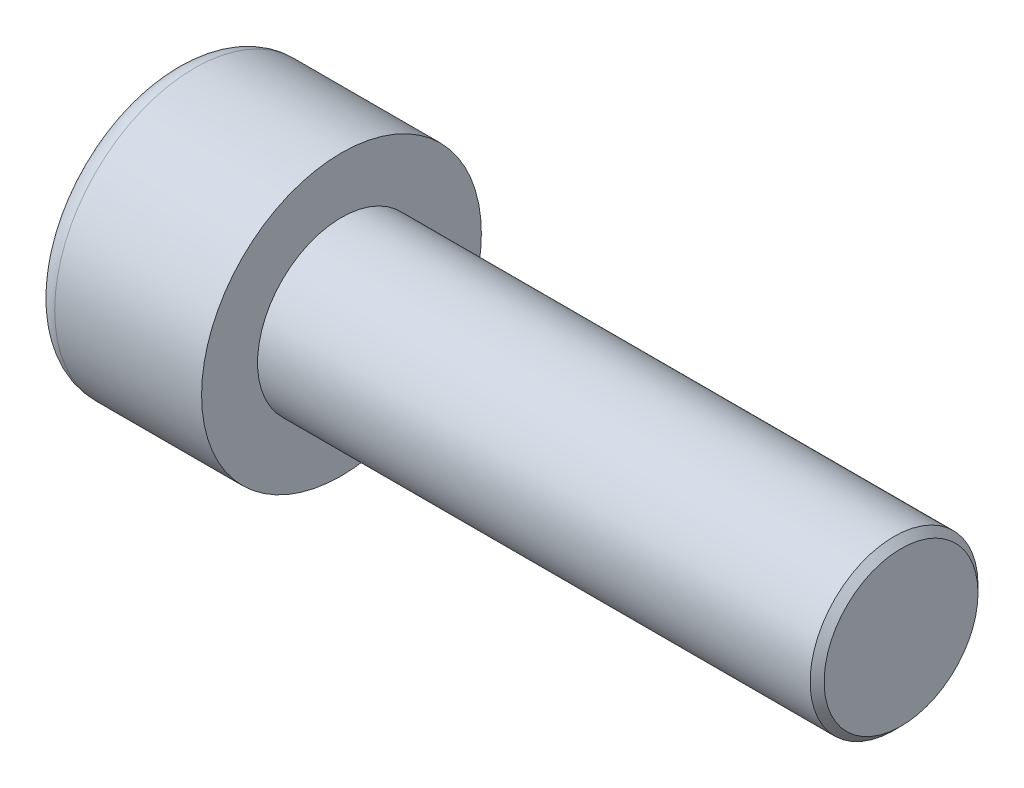
from build123d import *

# Parameters (mm, degrees)
SKETCH1_R           = 5
BASEHEAD_DEPTH      = 6
SKETCH2_R           = 3
BASEBODY_DEPTH      = 20
HEXAGONSOCKET_DEPTH = 3
TOPFILLET_R         = 0.75
CHAMFER1_SIZE       = 0.25


with BuildPart() as part:
    # Sketch1 → BaseHead (new body)
    with BuildSketch(Plane(origin=(0, 0, 0), x_dir=(0, 0, -1), z_dir=(1, 0, 0))):
        Circle(SKETCH1_R)
    extrude(amount=BASEHEAD_DEPTH)

    # Sketch2 → BaseBody (add)
    with BuildSketch(Plane(origin=(6, 0, 0), x_dir=(0, 0, -1), z_dir=(1, 0, 0))):
        Circle(SKETCH2_R)
    extrude(amount=BASEBODY_DEPTH)

    # Sketch3 → HexagonSocket (cut)
    with BuildSketch(Plane(origin=(0, 0, 0), x_dir=(0, 0, -1), z_dir=(1, 0, 0))):
        Polygon((2.886751346, 0), (1.443375673, 2.5), (-1.443375673, 2.5), (-2.886751346, 0), (-1.443375673, -2.5), (1.443375673, -2.5), align=None)
    extrude(amount=HEXAGONSOCKET_DEPTH, mode=Mode.SUBTRACT)

    # Sketch4 → Cut-Revolve1 (revolve, cut)
    with BuildSketch(Plane(origin=(-4.19613823, 0.75, 0), x_dir=(-1, 0, 0), z_dir=(0, 0, 1))):
        Polygon((-7.19613823, 3.25), (-8.639513903, 0.75), (-7.19613823, 0.75), align=None)
    revolve(axis=Axis((0.838992387, 0, 0), (-1, 0, 0)), mode=Mode.SUBTRACT)

    # TopFillet
    topfillet_edges = [part.edges().sort_by_distance(p)[0] for p in [
        (0, 0, 5),
    ]]
    fillet(topfillet_edges, radius=TOPFILLET_R)

    # Chamfer1
    chamfer1_edges = [part.edges().sort_by_distance(p)[0] for p in [
        (26, 0, 3),
    ]]
    chamfer(chamfer1_edges, length=CHAMFER1_SIZE)


solid = part.part
